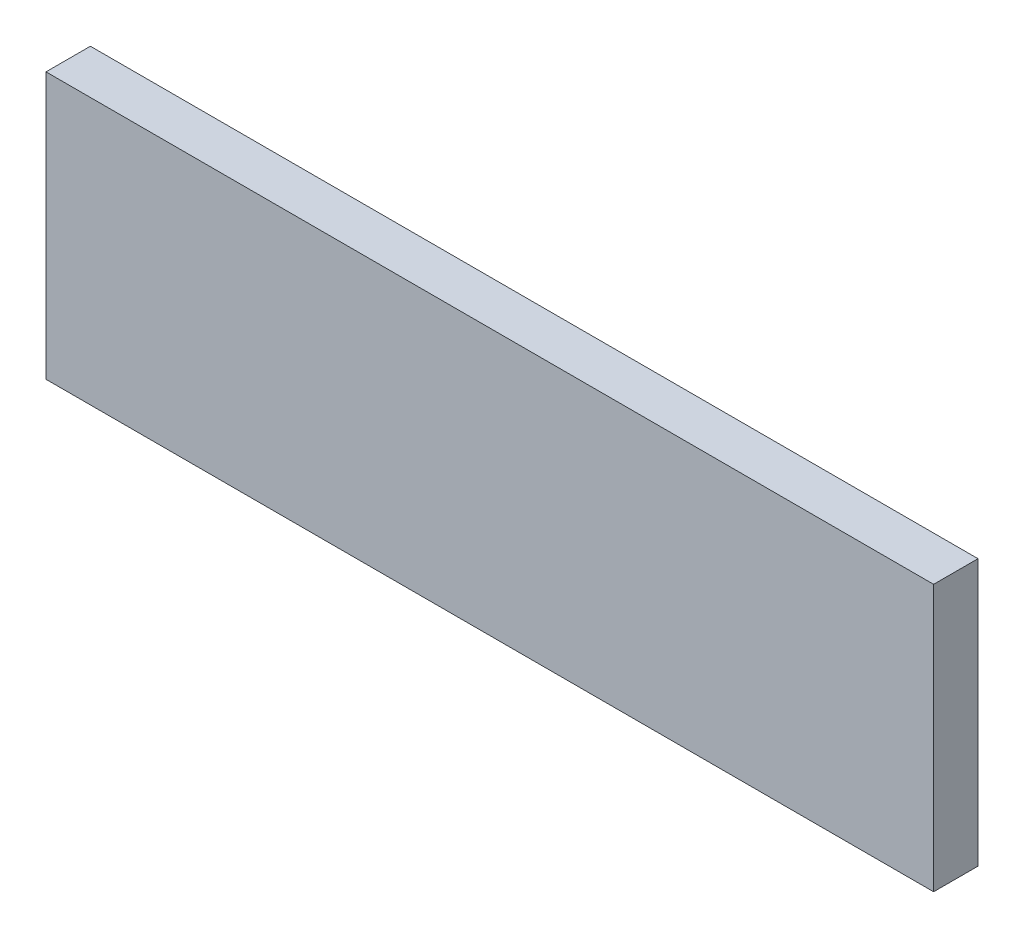
from build123d import *

# Parameters (mm, degrees)
SKETCH1_W           = 2000
SKETCH1_H           = 600
BOSS_EXTRUDE1_DEPTH = 100


with BuildPart() as part:
    # Sketch1 → Boss-Extrude1 (new body)
    with BuildSketch(Plane.XY):
        with Locations((-1000, -300)):
            Rectangle(SKETCH1_W, SKETCH1_H)
    extrude(amount=BOSS_EXTRUDE1_DEPTH)


solid = part.part
